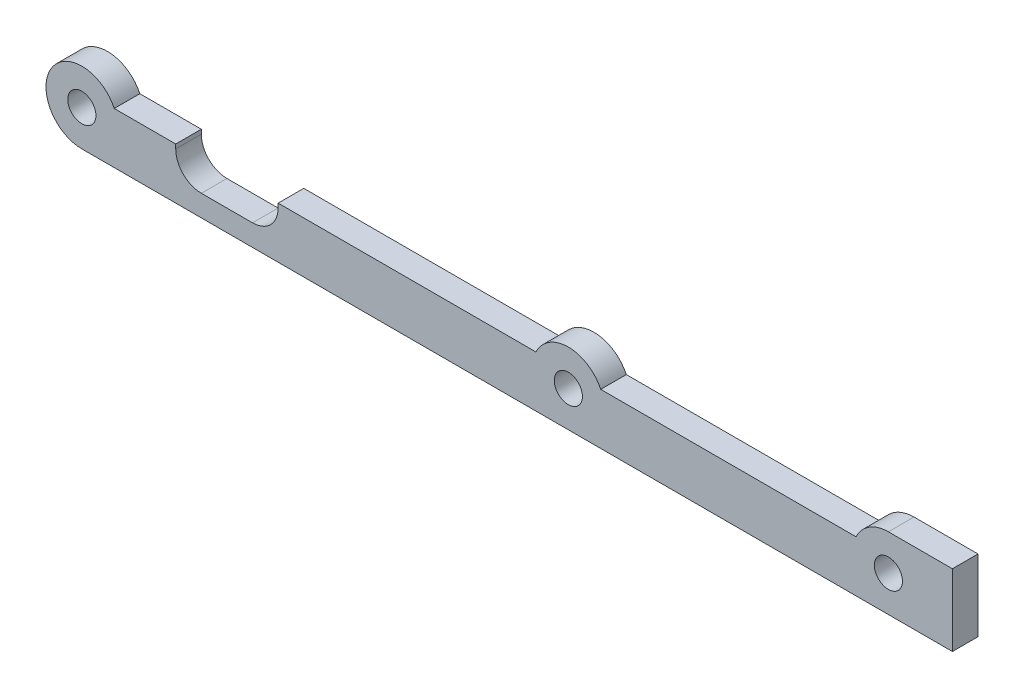
from build123d import *

# Parameters (mm, degrees)
SKETCH1_R           = 1.65
BOSS_EXTRUDE1_DEPTH = 3
FILLET1_R           = 3


with BuildPart() as part:
    # Sketch1 → Boss-Extrude1 (new body)
    with BuildSketch(Plane.XY):
        with BuildLine():
            Line((-53.205266808, 1.8), (-46, 1.8))
            Line((-46, 1.8), (-46, -1.7))
            Line((-46, -1.7), (-34, -1.7))
            Line((-34, -1.7), (-34, 1.8))
            Line((-34, 1.8), (-3.794733192, 1.8))
            ThreePointArc((-3.794733192, 1.8), (0, 4.2), (3.794733192, 1.8))
            Line((3.794733192, 1.8), (33.705266808, 1.8))
            ThreePointArc((33.705266808, 1.8), (35.255005568, 3.54964787), (37.5, 4.2))
            Line((37.5, 4.2), (45, 4.2))
            Line((45, 4.2), (45, -4.2))
            Line((45, -4.2), (-57, -4.2))
            ThreePointArc((-57, -4.2), (-60.54964787, 2.244994432), (-53.205266808, 1.8))
        make_face()
        Circle(SKETCH1_R, mode=Mode.SUBTRACT)
        with Locations((-57, 0)):
            Circle(SKETCH1_R, mode=Mode.SUBTRACT)
        with Locations((37.5, 0)):
            Circle(SKETCH1_R, mode=Mode.SUBTRACT)
    extrude(amount=BOSS_EXTRUDE1_DEPTH)

    # Fillet1
    fillet1_edges = [part.edges().sort_by_distance(p)[0] for p in [
        (-46, -1.7, 1.5),
        (-34, -1.7, 1.5),
    ]]
    fillet(fillet1_edges, radius=FILLET1_R)


solid = part.part
